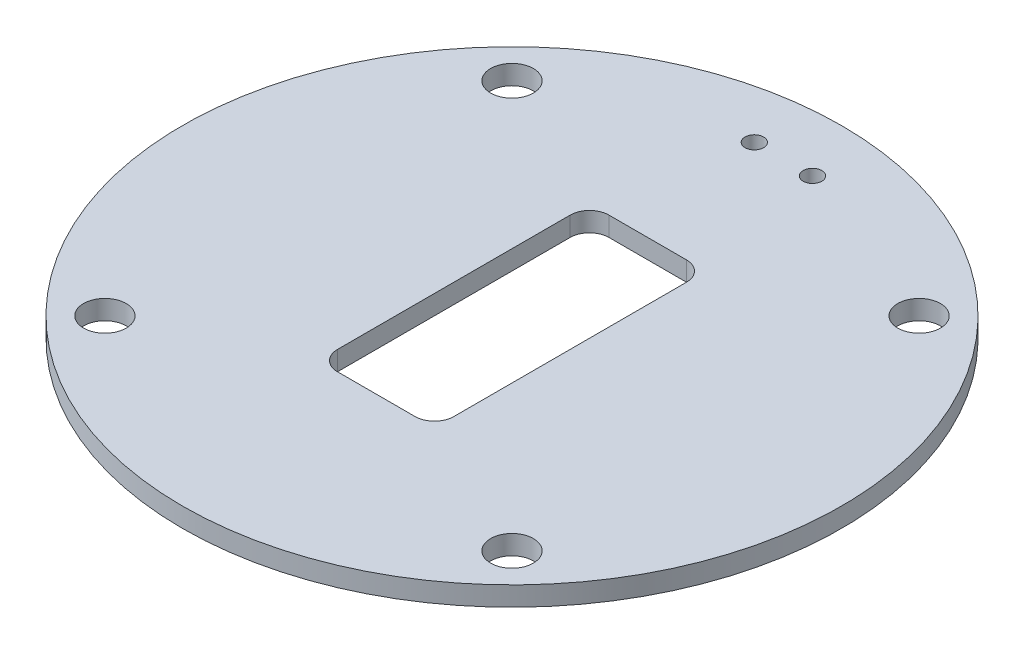
from build123d import *

# Parameters (mm, degrees)
SKETCH1_R          = 85
BASE_DEPTH         = 5
BOLT_HOLES_REACH   = 7
SKETCH2_R          = 5.5
SLOT_REACH         = 7
SKETCH5_R          = 2.4
SWITCH_HOLES_DEPTH = 5


with BuildPart() as part:
    # Sketch1 → Base (new body)
    with BuildSketch(Plane(origin=(0, 0, 0), x_dir=(1, 0, 0), z_dir=(0, 1, 0))):
        Circle(SKETCH1_R)
    extrude(amount=BASE_DEPTH)

    # Sketch2 → Bolt Holes (cut, up to next)
    with BuildSketch(Plane(origin=(0, 5, 0), x_dir=(1, 0, 0), z_dir=(0, 1, 0)), mode=Mode.PRIVATE) as bolt_holes_sk1:
        with Locations((52.5, 52.5)):
            Circle(SKETCH2_R)
    bolt_holes_tool1 = extrude(bolt_holes_sk1.sketch, amount=-BOLT_HOLES_REACH, mode=Mode.PRIVATE) & part.part
    add(bolt_holes_tool1.solids().sort_by_distance((52.5, 5, -52.5))[0], mode=Mode.SUBTRACT)
    # Sketch2 → Bolt Holes (cut, up to next)
    with BuildSketch(Plane(origin=(0, 5, 0), x_dir=(1, 0, 0), z_dir=(0, 1, 0)), mode=Mode.PRIVATE) as bolt_holes_sk2:
        with Locations((-52.5, 52.5)):
            Circle(SKETCH2_R)
    bolt_holes_tool2 = extrude(bolt_holes_sk2.sketch, amount=-BOLT_HOLES_REACH, mode=Mode.PRIVATE) & part.part
    add(bolt_holes_tool2.solids().sort_by_distance((-52.5, 5, -52.5))[0], mode=Mode.SUBTRACT)
    # Sketch2 → Bolt Holes (cut, up to next)
    with BuildSketch(Plane(origin=(0, 5, 0), x_dir=(1, 0, 0), z_dir=(0, 1, 0)), mode=Mode.PRIVATE) as bolt_holes_sk3:
        with Locations((52.5, -52.5)):
            Circle(SKETCH2_R)
    bolt_holes_tool3 = extrude(bolt_holes_sk3.sketch, amount=-BOLT_HOLES_REACH, mode=Mode.PRIVATE) & part.part
    add(bolt_holes_tool3.solids().sort_by_distance((52.5, 5, 52.5))[0], mode=Mode.SUBTRACT)
    # Sketch2 → Bolt Holes (cut, up to next)
    with BuildSketch(Plane(origin=(0, 5, 0), x_dir=(1, 0, 0), z_dir=(0, 1, 0)), mode=Mode.PRIVATE) as bolt_holes_sk4:
        with Locations((-52.5, -52.5)):
            Circle(SKETCH2_R)
    bolt_holes_tool4 = extrude(bolt_holes_sk4.sketch, amount=-BOLT_HOLES_REACH, mode=Mode.PRIVATE) & part.part
    add(bolt_holes_tool4.solids().sort_by_distance((-52.5, 5, 52.5))[0], mode=Mode.SUBTRACT)

    # Sketch4 → Slot (cut, up to next)
    with BuildSketch(Plane(origin=(0, 5, 0), x_dir=(1, 0, 0), z_dir=(0, 1, 0)), mode=Mode.PRIVATE) as slot_sk1:
        with BuildLine():
            Line((10, -35), (-10, -35))
            ThreePointArc((-10, -35), (-13.535533906, -33.535533906), (-15, -30))
            Line((-15, -30), (-15, 30))
            ThreePointArc((-15, 30), (-13.535533906, 33.535533906), (-10, 35))
            Line((-10, 35), (10, 35))
            ThreePointArc((10, 35), (13.535533906, 33.535533906), (15, 30))
            Line((15, 30), (15, -30))
            ThreePointArc((15, -30), (13.535533906, -33.535533906), (10, -35))
        make_face()
    slot_tool1 = extrude(slot_sk1.sketch, amount=-SLOT_REACH, mode=Mode.PRIVATE) & part.part
    add(slot_tool1.solids().sort_by_distance((0, 5, 0))[0], mode=Mode.SUBTRACT)

    # Sketch5 → Switch Holes (cut)
    with BuildSketch(Plane(origin=(0, 5, 0), x_dir=(1, 0, 0), z_dir=(0, 1, 0))):
        with Locations((7.5, 70)):
            Circle(SKETCH5_R)
        with Locations((-7.5, 70)):
            Circle(SKETCH5_R)
    extrude(amount=-SWITCH_HOLES_DEPTH, mode=Mode.SUBTRACT)


solid = part.part
